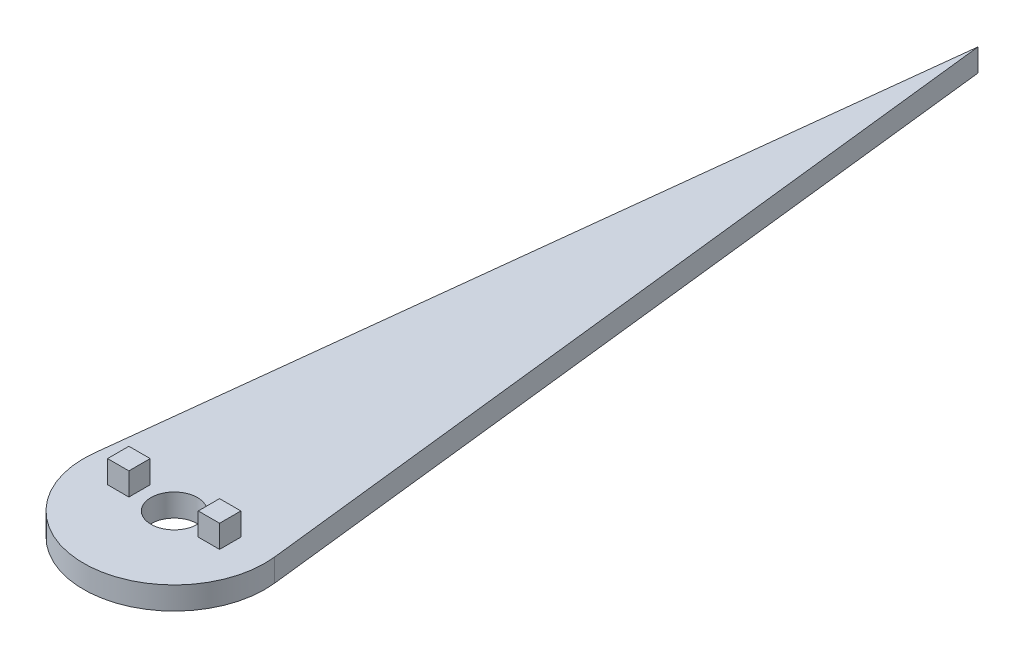
from build123d import *

# Parameters (mm, degrees)
SKETCH1_R           = 5.125
BOSS_EXTRUDE1_DEPTH = 5
SKETCH2_W           = 4.7
SKETCH2_H           = 4.7
BOSS_EXTRUDE2_DEPTH = 5


with BuildPart() as part:
    # Sketch1 → Boss-Extrude1 (new body)
    with BuildSketch(Plane(origin=(0, 0, 0), x_dir=(1, 0, 0), z_dir=(0, 1, 0))):
        with BuildLine():
            Line((-19.872284397, 2.256615355), (0, 177.256615355))
            Line((0, 177.256615355), (19.872284397, 2.256615355))
            ThreePointArc((19.872284397, 2.256615355), (0, -20), (-19.872284397, 2.256615355))
        make_face()
        Circle(SKETCH1_R, mode=Mode.SUBTRACT)
    extrude(amount=BOSS_EXTRUDE1_DEPTH)

    # Sketch2 → Boss-Extrude2 (add)
    with BuildSketch(Plane(origin=(0, 5, 0), x_dir=(1, 0, 0), z_dir=(0, 1, 0))):
        with Locations((10, 0)):
            Rectangle(SKETCH2_W, SKETCH2_H)
        with Locations((-10, 0)):
            Rectangle(SKETCH2_W, SKETCH2_H)
    extrude(amount=BOSS_EXTRUDE2_DEPTH)


solid = part.part
